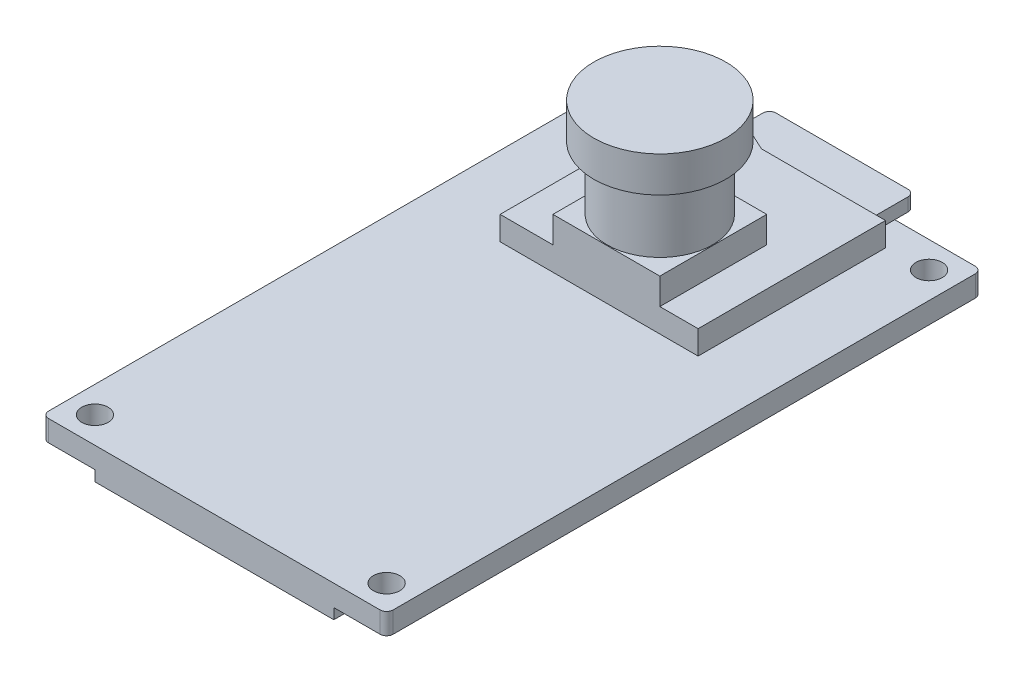
from build123d import *

# Parameters (mm, degrees)
SKETCH_1_W       = 26.1
SKETCH_1_H       = 45.1
SKETCH_1_R       = 1
EXTRUDE_1_DEPTH  = 1.6
EXTRUDE_2_DEPTH  = 1.8
SKETCH_3_W       = 11
SKETCH_3_H       = 1
EXTRUDE_3_DEPTH  = 3
FILLET_1_R       = 0.5
SKETCH_4_W       = 8.1
SKETCH_4_H       = 8.1
EXTRUDE_4_DEPTH  = 2
SKETCH_5_R       = 4
EXTRUDE_5_DEPTH  = 4.8
SKETCH_6_R       = 5
EXTRUDE_6_DEPTH  = 2.7
SKETCH_7_W       = 12.5
SKETCH_7_H       = 7.7
EXTRUDE_7_DEPTH  = 6
SKETCH_9_W       = 1.2
SKETCH_9_H       = 4.4
EXTRUDE_8_DEPTH  = 2.9
SKETCH_10_W      = 18.1
SKETCH_10_H      = 25.5
EXTRUDE_9_DEPTH  = 0.8
SKETCH_11_W      = 15.86
SKETCH_11_H      = 17.74
EXTRUDE_10_DEPTH = 2.3
SKETCH_12_W      = 0.88
SKETCH_12_H      = 2
EXTRUDE_11_DEPTH = 0.8


with BuildPart() as part:
    # 草图1 → 凸台-拉伸1 (new body)
    with BuildSketch(Plane(origin=(0, 0, 0), x_dir=(1, 0, 0), z_dir=(0, 1, 0))):
        Rectangle(SKETCH_1_W, SKETCH_1_H)
        with Locations((-11.05, 20.55)):
            Circle(SKETCH_1_R, mode=Mode.SUBTRACT)
        with Locations((11.05, 20.55)):
            Circle(SKETCH_1_R, mode=Mode.SUBTRACT)
        with Locations((-11.05, -20.55)):
            Circle(SKETCH_1_R, mode=Mode.SUBTRACT)
        with Locations((11.05, -20.55)):
            Circle(SKETCH_1_R, mode=Mode.SUBTRACT)
    extrude(amount=EXTRUDE_1_DEPTH)

    # 草图2 → 凸台-拉伸2 (add)
    with BuildSketch(Plane(origin=(0, 1.6, 0), x_dir=(1, 0, 0), z_dir=(0, 1, 0))):
        Polygon((-7.05, 6.15), (7.95, 6.15), (7.95, 20.35), (-1.45, 20.35), (-2.75, 20.95), (-7.05, 20.95), align=None)
    extrude(amount=EXTRUDE_2_DEPTH)

    # 草图3 → 凸台-拉伸3 (add)
    with BuildSketch(Plane(origin=(0, 0, -20.35), x_dir=(-1, 0, 0), z_dir=(0, 0, -1))):
        with Locations((-1.65, 2.8)):
            Rectangle(SKETCH_3_W, SKETCH_3_H)
    extrude(amount=EXTRUDE_3_DEPTH)

    # 圆角1
    fillet_1_edges = [part.edges().sort_by_distance(p)[0] for p in [
        (-3.85, 2.8, -23.35),
        (7.15, 2.8, -23.35),
        (13.05, 0.8, -22.55),
        (13.05, 0.8, 22.55),
        (-13.05, 0.8, 22.55),
        (-13.05, 0.8, -22.55),
    ]]
    fillet(fillet_1_edges, radius=FILLET_1_R)

    # 草图4 → 凸台-拉伸4 (add)
    with BuildSketch(Plane(origin=(0, 3.4, 0), x_dir=(1, 0, 0), z_dir=(0, 1, 0))):
        with Locations((1, 10.2)):
            Rectangle(SKETCH_4_W, SKETCH_4_H)
    extrude(amount=EXTRUDE_4_DEPTH)

    # 草图5 → 凸台-拉伸5 (add)
    with BuildSketch(Plane(origin=(0, 5.4, 0), x_dir=(1, 0, 0), z_dir=(0, 1, 0))):
        with Locations((1, 10.2)):
            Circle(SKETCH_5_R)
    extrude(amount=EXTRUDE_5_DEPTH)

    # 草图6 → 凸台-拉伸6 (add)
    with BuildSketch(Plane(origin=(0, 10.2, 0), x_dir=(1, 0, 0), z_dir=(0, 1, 0))):
        with Locations((1, 10.2)):
            Circle(SKETCH_6_R)
    extrude(amount=EXTRUDE_6_DEPTH)

    # 草图7 → 凸台-拉伸7 (add)
    with BuildSketch(Plane.XZ):
        with Locations((0.3, -18.5)):
            Rectangle(SKETCH_7_W, SKETCH_7_H)
    extrude(amount=EXTRUDE_7_DEPTH)

    # 草图9 → 凸台-拉伸8 (add)
    with BuildSketch(Plane.XZ):
        with Locations((7.15, -19.35)):
            Rectangle(SKETCH_9_W, SKETCH_9_H)
        with Locations((-6.55, -19.35)):
            Rectangle(SKETCH_9_W, SKETCH_9_H)
    extrude(amount=EXTRUDE_8_DEPTH)

    # 草图10 → 凸台-拉伸9 (add)
    with BuildSketch(Plane.XZ):
        with Locations((0, 9.8)):
            Rectangle(SKETCH_10_W, SKETCH_10_H)
    extrude(amount=EXTRUDE_9_DEPTH)

    # 草图11 → 凸台-拉伸10 (add)
    with BuildSketch(Plane.XZ.offset(0.8)):
        with Locations((-0.05, 6.99)):
            Rectangle(SKETCH_11_W, SKETCH_11_H)
    extrude(amount=EXTRUDE_10_DEPTH)

    # 草图12 → 凸台-拉伸11 (add)
    with BuildSketch(Plane.XZ):
        with Locations((-11.46, 16.55)):
            Rectangle(SKETCH_12_W, SKETCH_12_H)
        with Locations((-11.46, 13.55)):
            Rectangle(SKETCH_12_W, SKETCH_12_H)
        with Locations((-11.46, 10.55)):
            Rectangle(SKETCH_12_W, SKETCH_12_H)
        with Locations((-11.46, 7.55)):
            Rectangle(SKETCH_12_W, SKETCH_12_H)
        with Locations((-11.46, 4.55)):
            Rectangle(SKETCH_12_W, SKETCH_12_H)
    extrude(amount=EXTRUDE_11_DEPTH)


solid = part.part
